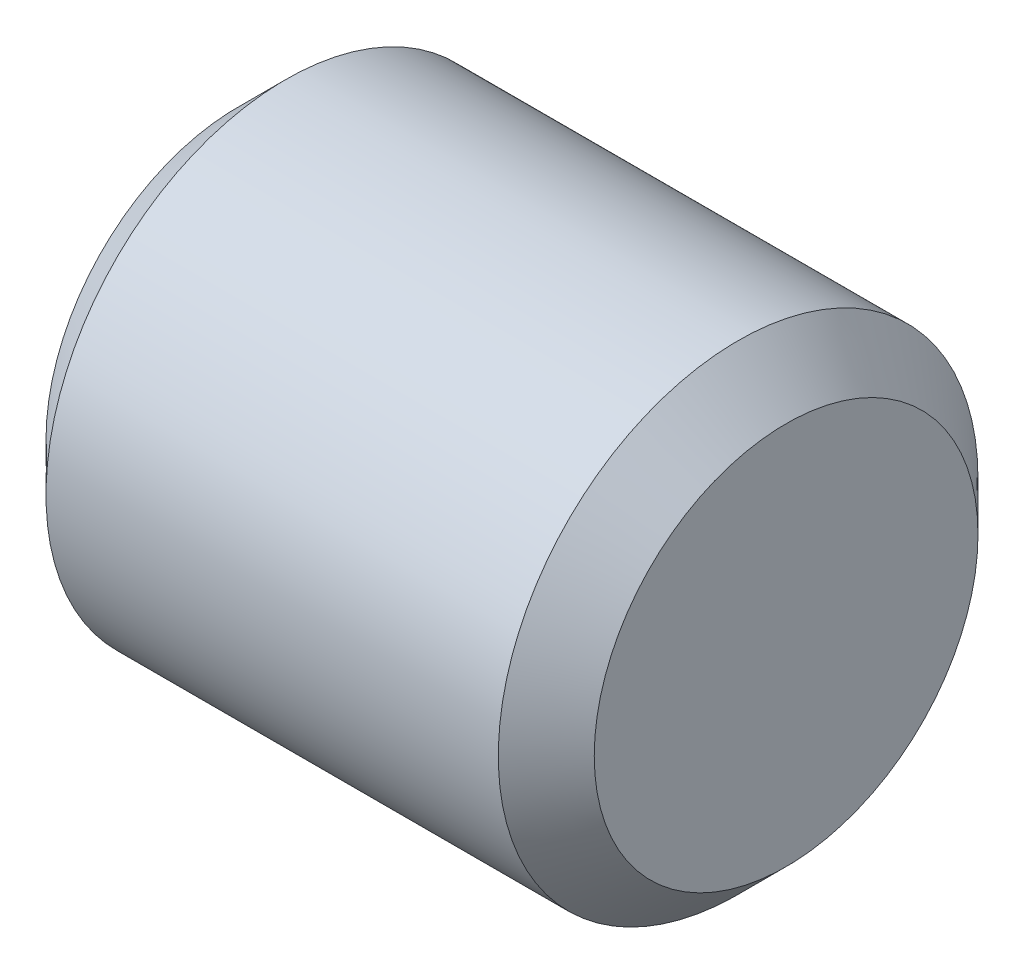
from build123d import *

# Parameters (mm, degrees)
SKETCH2_R           = 5.55625
EXTRUDE1_DEPTH      = 6.35
EXTRUDE1_DEPTH_BACK = 6.35
CHAMFER1_SIZE       = 1.11125


with BuildPart() as part:
    # Sketch2 → Extrude1 (new body, two sides)
    with BuildSketch(Plane(origin=(0, 0, 0), x_dir=(0, 0, -1), z_dir=(1, 0, 0))) as extrude1_sk:
        Circle(SKETCH2_R)
    extrude(amount=EXTRUDE1_DEPTH)
    extrude(extrude1_sk.sketch, amount=-EXTRUDE1_DEPTH_BACK)

    # Chamfer1
    chamfer1_edges = [part.edges().sort_by_distance(p)[0] for p in [
        (-6.35, 0, 5.55625),
        (6.35, 0, 5.55625),
    ]]
    chamfer(chamfer1_edges, length=CHAMFER1_SIZE)


solid = part.part
